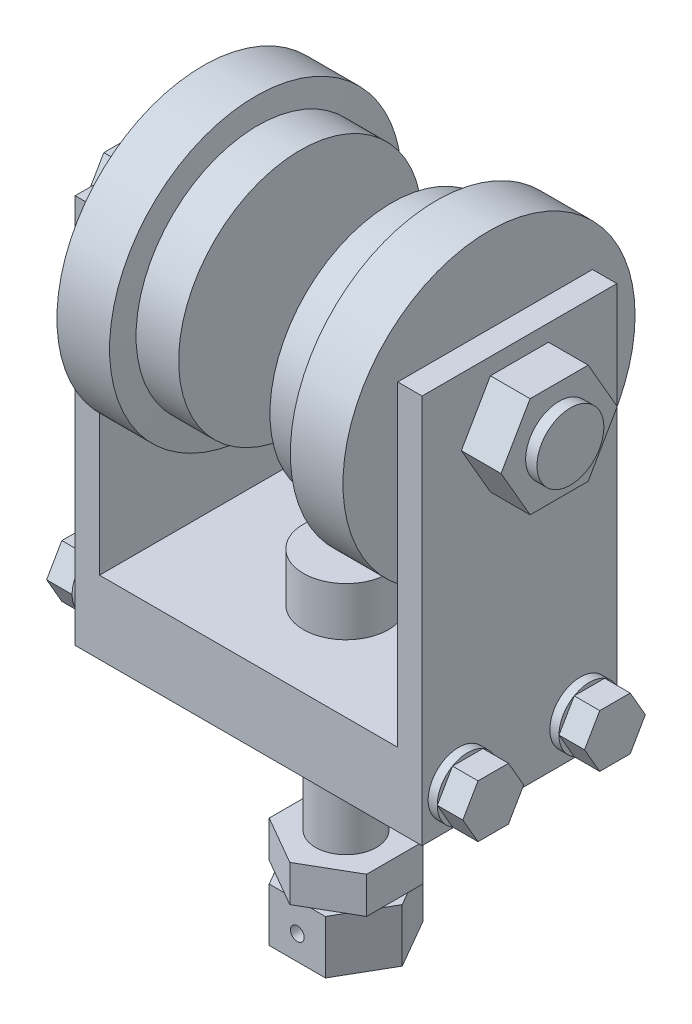
from build123d import *

# Parameters (mm, degrees)
YOKE_CROSS_SECTION_W           = 101.6
YOKE_CROSS_SECTION_H           = 38.1
YOKE_DEPTH                     = 77.7875
SIDEPLATE_PROFILE_W            = 101.6
SIDEPLATE_PROFILE_H            = 203.2
SIDEPLATE_DEPTH                = 12.7
WHEEL_PIN_NUT_DEPTH            = 20.70608
WHEEL_PIN_PROJECTION_PROFILE_R = 17.4625
WHEEL_PIN_PROJECTION_DEPTH     = 5.88264
LOCKNUTS_PROFILE_R             = 15.875
LOCKNUTS_DEPTH                 = 4.7625
SCREWS_DEPTH                   = 13.3223
PROFILE_R                      = 22.225
KING_BOLT_HEAD_DEPTH           = 25.4
DIA_R                          = 15.875
KING_BOLT_DEPTH                = 63.5
KING_BOLT_JAM_NUT_DEPTH        = 19.0754
KING_BOLT_NUT_DEPTH            = 27.8003
SKETCH5_R                      = 15.875
EXTENDED_KING_BOLT_DEPTH       = 6.35
CHAMFER1_SIZE                  = 2.38125
COTTER_PIN_HOLE_REACH          = 103.6
SKETCH7_R                      = 3.571875


with BuildPart() as part:
    # YOKE CROSS SECTION → YOKE (new body)
    with BuildSketch(Plane(origin=(0, 0, 0), x_dir=(0, 0, -1), z_dir=(1, 0, 0))):
        with Locations((0, 19.05)):
            Rectangle(YOKE_CROSS_SECTION_W, YOKE_CROSS_SECTION_H)
    extrude(amount=YOKE_DEPTH)

    # SIDEPLATE PROFILE → SIDEPLATE (add)
    with BuildSketch(Plane(origin=(77.7875, 0, 0), x_dir=(0, 0, -1), z_dir=(1, 0, 0))):
        with Locations((0, 101.6)):
            Rectangle(SIDEPLATE_PROFILE_W, SIDEPLATE_PROFILE_H)
    extrude(amount=SIDEPLATE_DEPTH)

    # WHEEL PIN NUT PROFILE → WHEEL PIN NUT (add)
    with BuildSketch(Plane(origin=(90.4875, 0, 0), x_dir=(0, 0, -1), z_dir=(1, 0, 0))):
        Polygon((30.301663075, 168.275), (15.150831538, 194.51701), (-15.150831538, 194.51701), (-30.301663075, 168.275), (-15.150831538, 142.03299), (15.150831538, 142.03299), align=None)
    extrude(amount=WHEEL_PIN_NUT_DEPTH)

    # WHEEL PIN PROJECTION PROFILE → WHEEL PIN PROJECTION (add)
    with BuildSketch(Plane(origin=(111.19358, 0, 0), x_dir=(0, 0, -1), z_dir=(1, 0, 0))):
        with Locations((0, 168.275)):
            Circle(WHEEL_PIN_PROJECTION_PROFILE_R)
    extrude(amount=WHEEL_PIN_PROJECTION_DEPTH)

    # LOCKNUTS PROFILE → LOCKNUTS (add)
    with BuildSketch(Plane(origin=(90.4875, 0, 0), x_dir=(0, 0, -1), z_dir=(1, 0, 0))):
        with Locations((-31.75, 19.05)):
            Circle(LOCKNUTS_PROFILE_R)
    locknuts = extrude(amount=LOCKNUTS_DEPTH)

    # SCREWS PROFILE → SCREWS (add)
    with BuildSketch(Plane(origin=(95.25, 0, 0), x_dir=(0, 0, -1), z_dir=(1, 0, 0))):
        Polygon((-15.875465673, 19.05), (-23.812732837, 32.79775), (-39.687267163, 32.79775), (-47.624534327, 19.05), (-39.687267163, 5.30225), (-23.812732837, 5.30225), align=None)
    screws = extrude(amount=SCREWS_DEPTH)

    # PROFILE → KING BOLT HEAD (add)
    with BuildSketch(Plane(origin=(0, 38.1, 0), x_dir=(-1, 0, 0), z_dir=(0, 1, 0))):
        with Locations(Location((0, 0, 0), (0, 0, 90))):  # turned: the seam where the file's is
            Circle(PROFILE_R)
    extrude(amount=KING_BOLT_HEAD_DEPTH)

    # Mirror1: LOCKNUTS, SCREWS across plane
    add(locknuts.mirror(Plane.XY))
    add(screws.mirror(Plane.XY))

    # Mirror5: part across plane


with BuildPart() as part_1:
    add(part.part)
    add(part.part.mirror(Plane(origin=(0, 0, 0), x_dir=(0, 0, 1), z_dir=(1, 0, 0))))

    # DIA. → KING BOLT (add)
    with BuildSketch(Plane.XZ):
        with Locations(Location((0, 0, 0), (0, 0, 90))):  # turned: the seam where the file's is
            Circle(DIA_R)
    extrude(amount=KING_BOLT_DEPTH)

    # KING BOLT JAN NUT PROFILE → KING BOLT JAM NUT (add)
    with BuildSketch(Plane.XZ.offset(63.5)):
        Polygon((0, -29.329393675), (25.4, -14.664696837), (25.4, 14.664696837), (0, 29.329393675), (-25.4, 14.664696837), (-25.4, -14.664696837), align=None)
    extrude(amount=KING_BOLT_JAM_NUT_DEPTH)

    # KING BOLT NUT PROFILE → KING BOLT NUT (add)
    with BuildSketch(Plane.XZ.offset(82.5754)):
        Polygon((29.329393675, 0), (14.664696837, 25.4), (-14.664696837, 25.4), (-29.329393675, 0), (-14.664696837, -25.4), (14.664696837, -25.4), align=None)
    extrude(amount=KING_BOLT_NUT_DEPTH)

    # Sketch5 → EXTENDED KING BOLT (add)
    with BuildSketch(Plane.XZ.offset(110.3757)):
        with Locations(Location((0, 0, 0), (0, 0, 90))):  # turned: the seam where the file's is
            Circle(SKETCH5_R)
    extrude(amount=EXTENDED_KING_BOLT_DEPTH)

    # Chamfer1
    chamfer1_edges = [part_1.edges().sort_by_distance(p)[0] for p in [
        (0, -116.7257, -15.875),
    ]]
    chamfer(chamfer1_edges, length=CHAMFER1_SIZE)

    # Sketch6 → WHEEL (revolve)
    with BuildSketch(Plane.XY, mode=Mode.PRIVATE) as wheel_sk:
        Polygon((74.6125, 191.139897096), (74.6125, 244.475), (47.1551, 244.475), (46.0375, 231.775), (23.8125, 231.775), (23.8125, 168.275), (77.7875, 168.275), (77.7875, 191.139897096), align=None)
    wheel = revolve(wheel_sk.sketch.rotate(Axis((117.07622, 168.275, 0), (-1, 0, 0)), 90), axis=Axis((117.07622, 168.275, 0), (-1, 0, 0)))  # turned: the seam where the file's is

    # Mirror6: WHEEL across plane
    add(wheel.mirror(Plane(origin=(0, 0, 0), x_dir=(0, 0, 1), z_dir=(1, 0, 0))))

    # Sketch7 → COTTER PIN HOLE (cut, up to next)
    with BuildSketch(Plane.XY.offset(25.4), mode=Mode.PRIVATE) as cotter_pin_hole_sk1:
        with Locations((0, -97.6757)):
            Circle(SKETCH7_R)
    cotter_pin_hole_tool1 = extrude(cotter_pin_hole_sk1.sketch, amount=-COTTER_PIN_HOLE_REACH, mode=Mode.PRIVATE) & part_1.part
    add(cotter_pin_hole_tool1.solids().sort_by_distance((0, -97.6757, 25.4))[0], mode=Mode.SUBTRACT)


solid = part_1.part
